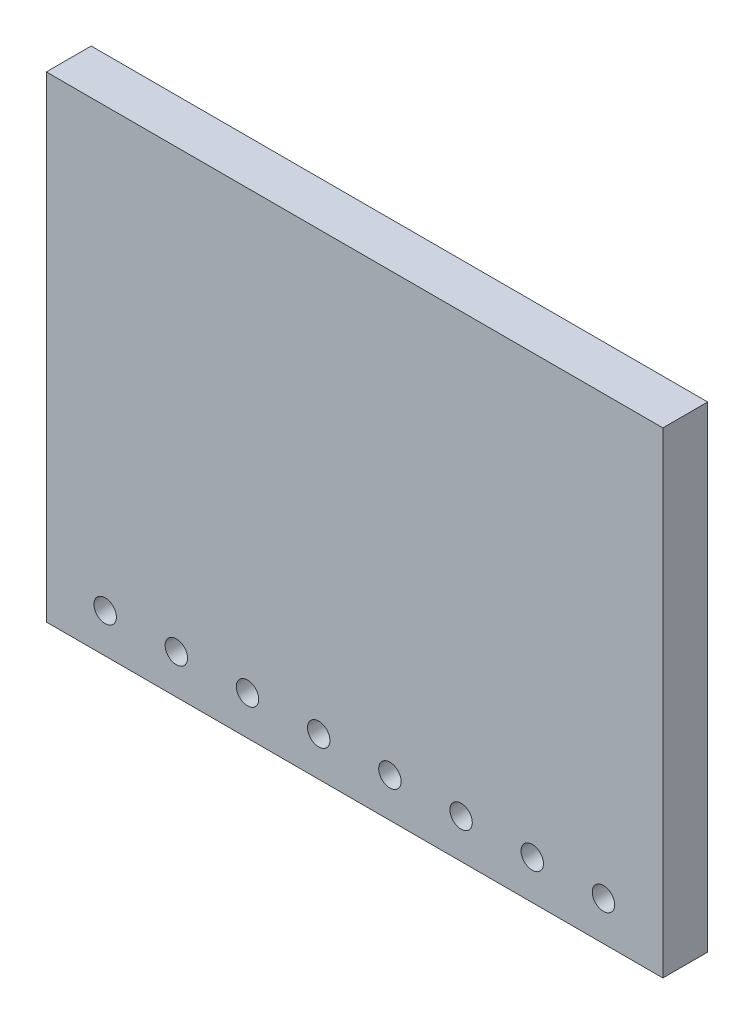
from build123d import *

# Parameters (mm, degrees)
SKETCH1_W           = 22
SKETCH1_H           = 17
BOSS_EXTRUDE1_DEPTH = 1.6
CUT_EXTRUDE1_REACH  = 3.6
SKETCH2_R           = 0.4


with BuildPart() as part:
    # Sketch1 → Boss-Extrude1 (new body)
    with BuildSketch(Plane.XY):
        Rectangle(SKETCH1_W, SKETCH1_H)
    extrude(amount=BOSS_EXTRUDE1_DEPTH)

    # Sketch2 → Cut-Extrude1 (cut, up to next)
    with BuildSketch(Plane.XY.offset(1.6), mode=Mode.PRIVATE) as cut_extrude1_sk1:
        with Locations((-8.9, -7.1)):
            Circle(SKETCH2_R)
    cut_extrude1_tool1 = extrude(cut_extrude1_sk1.sketch, amount=-CUT_EXTRUDE1_REACH, mode=Mode.PRIVATE) & part.part
    add(cut_extrude1_tool1.solids().sort_by_distance((-8.9, -7.1, 1.6))[0], mode=Mode.SUBTRACT)
    # Sketch2 → Cut-Extrude1 (cut, up to next)
    with BuildSketch(Plane.XY.offset(1.6), mode=Mode.PRIVATE) as cut_extrude1_sk2:
        with Locations((-6.36, -7.1)):
            Circle(SKETCH2_R)
    cut_extrude1_tool2 = extrude(cut_extrude1_sk2.sketch, amount=-CUT_EXTRUDE1_REACH, mode=Mode.PRIVATE) & part.part
    add(cut_extrude1_tool2.solids().sort_by_distance((-6.36, -7.1, 1.6))[0], mode=Mode.SUBTRACT)
    # Sketch2 → Cut-Extrude1 (cut, up to next)
    with BuildSketch(Plane.XY.offset(1.6), mode=Mode.PRIVATE) as cut_extrude1_sk3:
        with Locations((-3.82, -7.1)):
            Circle(SKETCH2_R)
    cut_extrude1_tool3 = extrude(cut_extrude1_sk3.sketch, amount=-CUT_EXTRUDE1_REACH, mode=Mode.PRIVATE) & part.part
    add(cut_extrude1_tool3.solids().sort_by_distance((-3.82, -7.1, 1.6))[0], mode=Mode.SUBTRACT)
    # Sketch2 → Cut-Extrude1 (cut, up to next)
    with BuildSketch(Plane.XY.offset(1.6), mode=Mode.PRIVATE) as cut_extrude1_sk4:
        with Locations((-1.28, -7.1)):
            Circle(SKETCH2_R)
    cut_extrude1_tool4 = extrude(cut_extrude1_sk4.sketch, amount=-CUT_EXTRUDE1_REACH, mode=Mode.PRIVATE) & part.part
    add(cut_extrude1_tool4.solids().sort_by_distance((-1.28, -7.1, 1.6))[0], mode=Mode.SUBTRACT)
    # Sketch2 → Cut-Extrude1 (cut, up to next)
    with BuildSketch(Plane.XY.offset(1.6), mode=Mode.PRIVATE) as cut_extrude1_sk5:
        with Locations((1.26, -7.1)):
            Circle(SKETCH2_R)
    cut_extrude1_tool5 = extrude(cut_extrude1_sk5.sketch, amount=-CUT_EXTRUDE1_REACH, mode=Mode.PRIVATE) & part.part
    add(cut_extrude1_tool5.solids().sort_by_distance((1.26, -7.1, 1.6))[0], mode=Mode.SUBTRACT)
    # Sketch2 → Cut-Extrude1 (cut, up to next)
    with BuildSketch(Plane.XY.offset(1.6), mode=Mode.PRIVATE) as cut_extrude1_sk6:
        with Locations((3.8, -7.1)):
            Circle(SKETCH2_R)
    cut_extrude1_tool6 = extrude(cut_extrude1_sk6.sketch, amount=-CUT_EXTRUDE1_REACH, mode=Mode.PRIVATE) & part.part
    add(cut_extrude1_tool6.solids().sort_by_distance((3.8, -7.1, 1.6))[0], mode=Mode.SUBTRACT)
    # Sketch2 → Cut-Extrude1 (cut, up to next)
    with BuildSketch(Plane.XY.offset(1.6), mode=Mode.PRIVATE) as cut_extrude1_sk7:
        with Locations((6.34, -7.1)):
            Circle(SKETCH2_R)
    cut_extrude1_tool7 = extrude(cut_extrude1_sk7.sketch, amount=-CUT_EXTRUDE1_REACH, mode=Mode.PRIVATE) & part.part
    add(cut_extrude1_tool7.solids().sort_by_distance((6.34, -7.1, 1.6))[0], mode=Mode.SUBTRACT)
    # Sketch2 → Cut-Extrude1 (cut, up to next)
    with BuildSketch(Plane.XY.offset(1.6), mode=Mode.PRIVATE) as cut_extrude1_sk8:
        with Locations((8.88, -7.1)):
            Circle(SKETCH2_R)
    cut_extrude1_tool8 = extrude(cut_extrude1_sk8.sketch, amount=-CUT_EXTRUDE1_REACH, mode=Mode.PRIVATE) & part.part
    add(cut_extrude1_tool8.solids().sort_by_distance((8.88, -7.1, 1.6))[0], mode=Mode.SUBTRACT)


solid = part.part
